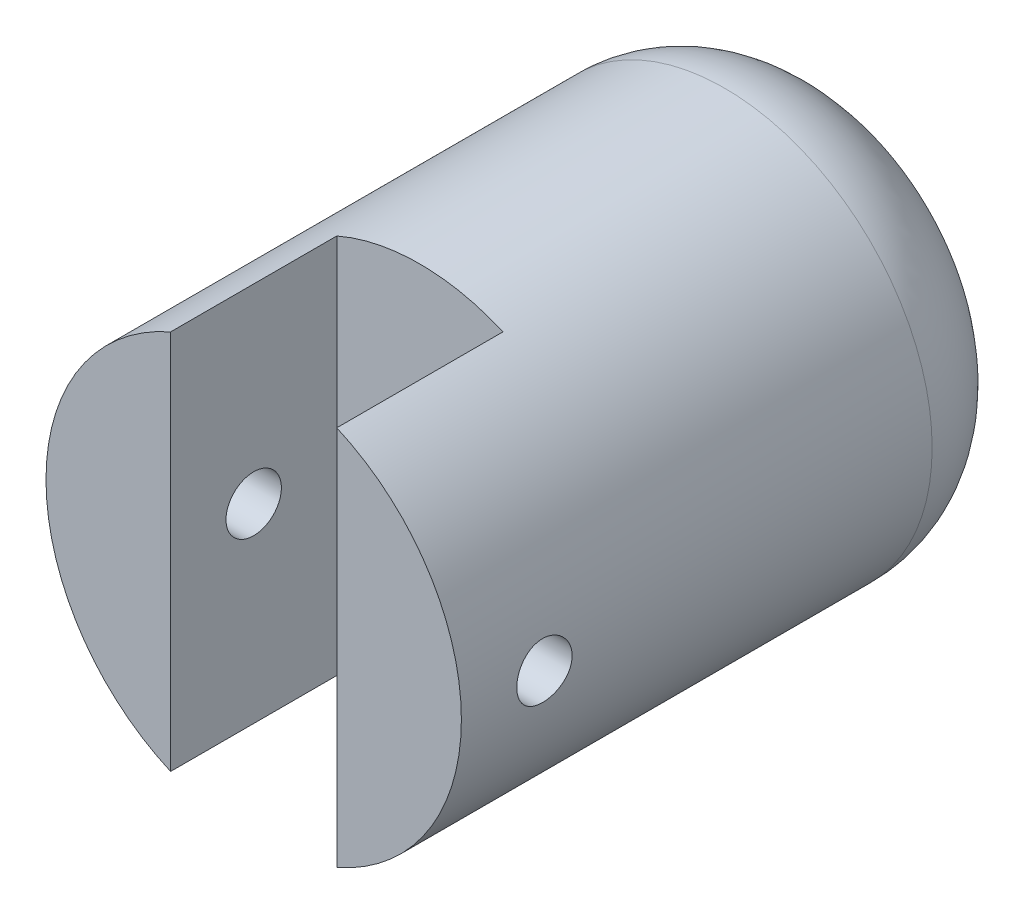
from build123d import *

# Parameters (mm, degrees)
CROQUIS1_R              = 7.5
SALIENTE_EXTRUIR1_DEPTH = 21
CROQUIS2_R              = 1
CORTAR_EXTRUIR1_DEPTH   = 10.5
CROQUIS3_W              = 6
CROQUIS3_H              = 18
CORTAR_EXTRUIR2_DEPTH   = 6
REDONDEO1_R             = 4


with BuildPart() as part:
    # Croquis1 → Saliente-Extruir1 (new body)
    with BuildSketch(Plane.XY):
        Circle(CROQUIS1_R)
    extrude(amount=SALIENTE_EXTRUIR1_DEPTH)

    # Croquis2 → Cortar-Extruir1 (cut, symmetric)
    with BuildSketch(Plane(origin=(0, 0, 0), x_dir=(0, 0, -1), z_dir=(1, 0, 0))):
        with Locations((-18, 0)):
            Circle(CROQUIS2_R)
    extrude(amount=CORTAR_EXTRUIR1_DEPTH, both=True, mode=Mode.SUBTRACT)

    # Croquis3 → Cortar-Extruir2 (cut)
    with BuildSketch(Plane.XY.offset(21)):
        Rectangle(CROQUIS3_W, CROQUIS3_H)
    extrude(amount=-CORTAR_EXTRUIR2_DEPTH, mode=Mode.SUBTRACT)

    # Redondeo1
    redondeo1_edges = [part.edges().sort_by_distance(p)[0] for p in [
        (-7.5, 0, 0),
    ]]
    fillet(redondeo1_edges, radius=REDONDEO1_R)


solid = part.part
